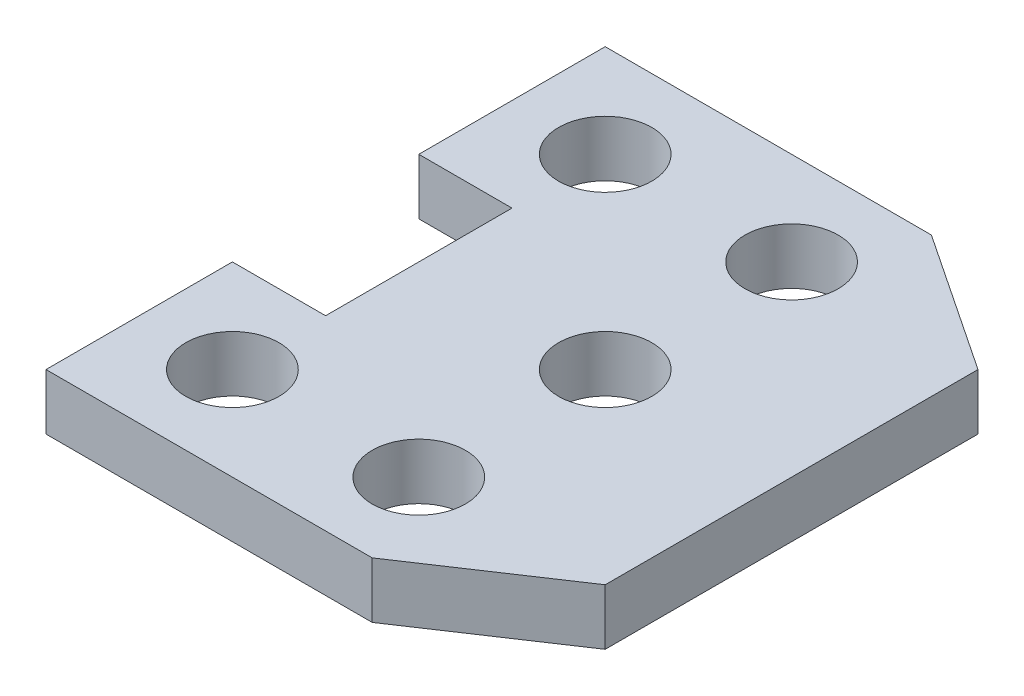
from build123d import *

# Parameters (mm, degrees)
SKETCH3_R           = 10
BOSS_EXTRUDE1_DEPTH = 12


with BuildPart() as part:
    # Sketch3 → Boss-Extrude1 (new body)
    with BuildSketch(Plane(origin=(0, 0, 0), x_dir=(1, 0, 0), z_dir=(0, 1, 0))):
        Polygon((0, 0), (-70, 0), (-70, 40), (-50, 40), (-50, 80), (-70, 80), (-70, 120), (0, 120), (30, 100), (30, 20), align=None)
        with Locations((-50, 100)):
            Circle(SKETCH3_R, mode=Mode.SUBTRACT)
        with Locations((-10, 100)):
            Circle(SKETCH3_R, mode=Mode.SUBTRACT)
        with Locations((-50, 20)):
            Circle(SKETCH3_R, mode=Mode.SUBTRACT)
        with Locations((-10, 20)):
            Circle(SKETCH3_R, mode=Mode.SUBTRACT)
        with Locations((-10, 60)):
            Circle(SKETCH3_R, mode=Mode.SUBTRACT)
    extrude(amount=BOSS_EXTRUDE1_DEPTH)


solid = part.part
